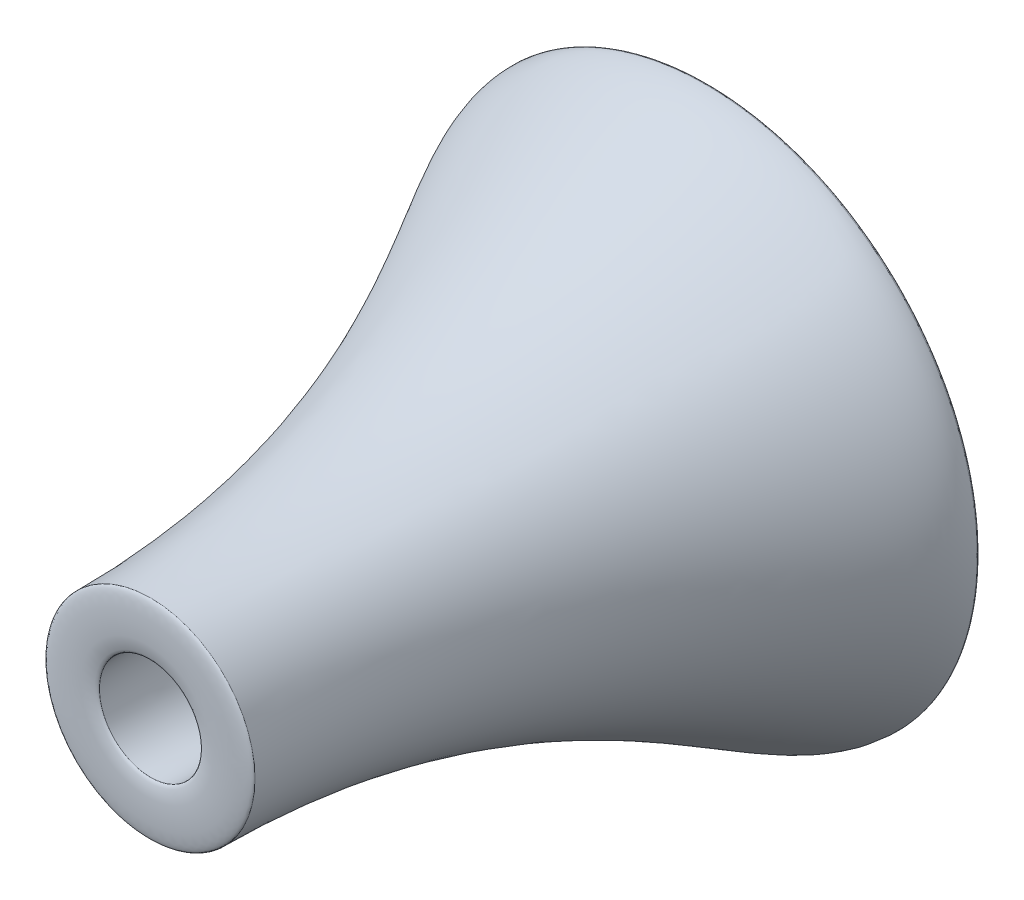
from build123d import *


with BuildPart() as part:
    # Sketch21 → Revolve2 (revolve)
    with BuildSketch(Plane(origin=(0, 0, 0), x_dir=(1, 0, 0), z_dir=(0, 1, 0))):
        with BuildLine():
            Line((-110.643738414, -1080.691222915), (-225.523950171, -1080.691222915))
            add(Edge.make_bspline(
                [(-587.893481305, 117.915687759), (-587.893481305, -7.468264617), (-225.523950171, -350.38210253), (-225.523950171, -1080.691222915)],
                knots=[0, 0, 0, 0, 1, 1, 1, 1], degree=3))
            Line((-587.893481305, 117.915687759), (-485.686690473, 117.915687759))
            add(Edge.make_bspline(
                [(-485.686690473, 117.915687759), (-485.686690473, 65.279935237), (-363.741093584, -68.883812009), (-348.563558656, -337.828003558), (-153.207908822, -723.874268625), (-110.643738414, -791.582602275), (-110.643738414, -1080.691222915)],
                knots=[0, 0, 0, 0, 0.158009172, 0.206506907, 0.484977351, 1, 1, 1, 1], degree=3))
        make_face()
    revolve(axis=Axis((0, 0, 99.684784321), (0, 0, -1)))


with BuildPart() as body_2:
    # Sketch22 → Revolve3 (revolve)
    with BuildSketch(Plane(origin=(0, 0, 0), x_dir=(1, 0, 0), z_dir=(0, 1, 0))):
        with BuildLine():
            Line((-587.893481305, 117.915687759), (-485.686690473, 117.915687759))
            add(Edge.make_bspline(
                [(-587.893481305, 117.915687759), (-587.893481305, 134.849021092), (-485.686690473, 134.849021092), (-485.686690473, 117.915687759)],
                knots=[0, 0, 0, 0, 1, 1, 1, 1], degree=3))
        make_face()
    revolve(axis=Axis((0, 0, 99.684784321), (0, 0, -1)))


with BuildPart() as body_3:
    # Sketch23 → Revolve4 (revolve)
    with BuildSketch(Plane(origin=(0, 0, 0), x_dir=(1, 0, 0), z_dir=(0, 1, 0))):
        with BuildLine():
            Line((-225.523950171, -1080.691222915), (-110.643738414, -1080.691222915))
            add(Edge.make_bspline(
                [(-225.523950171, -1080.691222915), (-225.523950171, -1093.391222915), (-110.643738414, -1093.391222915), (-110.643738414, -1080.691222915)],
                knots=[0, 0, 0, 0, 1, 1, 1, 1], degree=3))
        make_face()
    revolve(axis=Axis((0, 0, 1104.756830123), (0, 0, -1)))


solid = Compound([part.part, body_2.part, body_3.part])
